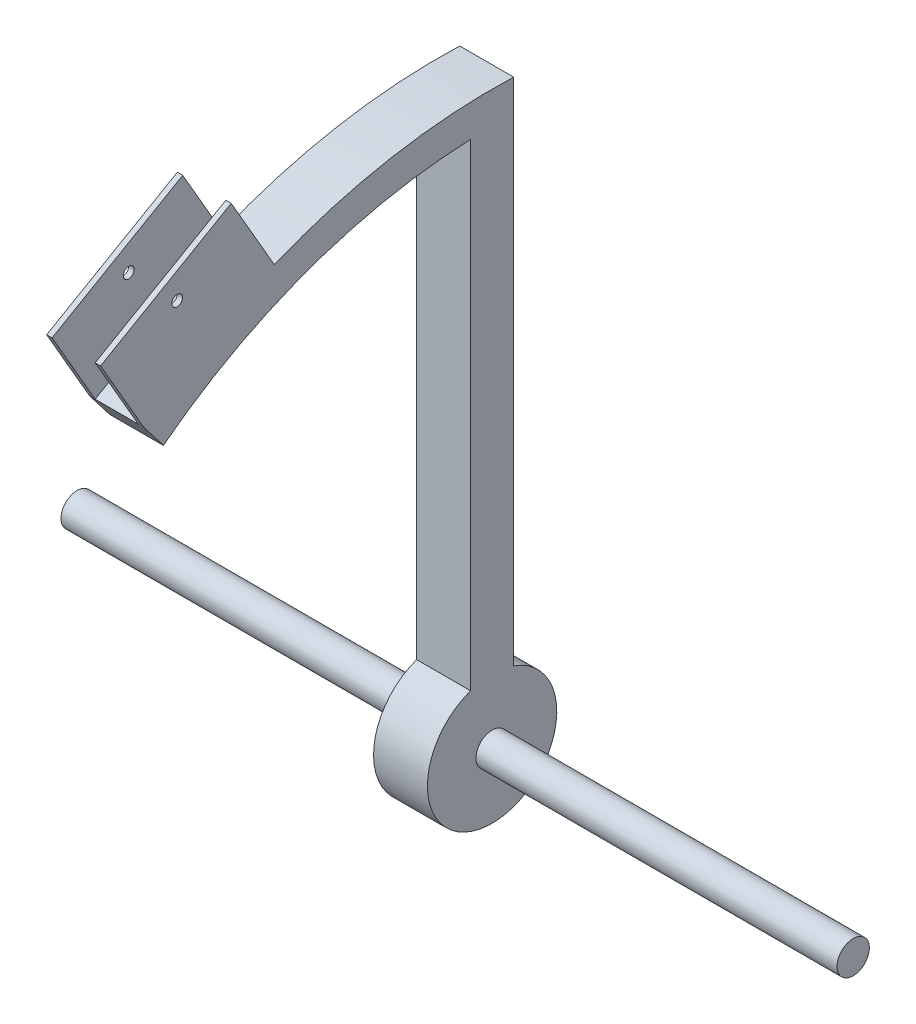
from build123d import *

# Parameters (mm, degrees)
BOSS_EXTRUDE1_DEPTH      = 12.5
BOSS_EXTRUDE1_DEPTH_BACK = 12.5
SKETCH11_R               = 7.5
BOSS_EXTRUDE4_DEPTH      = 180
BOSS_EXTRUDE4_DEPTH_BACK = 180
SKETCH12_W               = 25
SKETCH12_H               = 70
BOSS_EXTRUDE5_DEPTH      = 40
SKETCH13_W               = 20
SKETCH13_H               = 40
CUT_EXTRUDE2_DEPTH       = 70
SKETCH15_R               = 2.5
CUT_EXTRUDE3_DEPTH       = 191
CUT_EXTRUDE3_DEPTH_BACK  = 171
BOSS_EXTRUDE8_DEPTH      = 20


with BuildPart() as part:
    # Sketch1 → Boss-Extrude1 (new body, two sides)
    with BuildSketch(Plane(origin=(0, 0, 0), x_dir=(0, 0, -1), z_dir=(1, 0, 0))) as boss_extrude1_sk:
        with BuildLine():
            Line((10, 28.284271247), (10, 264.811253537))
            ThreePointArc((10, 264.811253537), (-46.581095136, 260.873918926), (-101.028366233, 244.986263322))
            Line((-101.028366233, 244.986263322), (-161.650144498, 209.986263322))
            Line((-161.650144498, 209.986263322), (-152.500136319, 198.100248417))
            ThreePointArc((-152.500136319, 198.100248417), (-85.263049352, 235.011089984), (-10, 249.799919936))
            Line((-10, 249.799919936), (-10, 28.284271247))
            ThreePointArc((-10, 28.284271247), (0, -30), (10, 28.284271247))
        make_face()
    extrude(amount=BOSS_EXTRUDE1_DEPTH)
    extrude(boss_extrude1_sk.sketch, amount=-BOSS_EXTRUDE1_DEPTH_BACK)

    # Sketch11 → Boss-Extrude4 (add, two sides)
    with BuildSketch(Plane(origin=(0, 0, 0), x_dir=(0, 0, -1), z_dir=(1, 0, 0))) as boss_extrude4_sk:
        Circle(SKETCH11_R)
    extrude(amount=BOSS_EXTRUDE4_DEPTH)
    extrude(boss_extrude4_sk.sketch, amount=-BOSS_EXTRUDE4_DEPTH_BACK)

    # Sketch12 → Boss-Extrude5 (add)
    with BuildSketch(Plane(origin=(0, 227.486263322, 131.339255366), x_dir=(1, 0, 0), z_dir=(0, 0.866025404, 0.5))):
        Rectangle(SKETCH12_W, SKETCH12_H)
    extrude(amount=BOSS_EXTRUDE5_DEPTH)

    # Sketch13 → Cut-Extrude2 (cut)
    with BuildSketch(Plane(origin=(0, 17.5, -30.310889132), x_dir=(-1, 0, 0), z_dir=(0, 0.5, -0.866025404))):
        with Locations((0, 282.678510731)):
            Rectangle(SKETCH13_W, SKETCH13_H)
    extrude(amount=-CUT_EXTRUDE2_DEPTH, mode=Mode.SUBTRACT)

    # Sketch15 → Cut-Extrude3 (cut, two sides)
    with BuildSketch(Plane.ZY.offset(-10)) as cut_extrude3_sk:
        with Locations((146.114255366, 253.077314003)):
            Circle(SKETCH15_R)
    extrude(amount=CUT_EXTRUDE3_DEPTH, mode=Mode.SUBTRACT)
    extrude(cut_extrude3_sk.sketch, amount=-CUT_EXTRUDE3_DEPTH_BACK, mode=Mode.SUBTRACT)

    # Sketch16 → Boss-Extrude8 (add)
    with BuildSketch(Plane.ZY.offset(-10)):
        Polygon((122.098874309, 241.48145385), (124.598874309, 245.811580869), (150.579636422, 230.811580869), (148.079636422, 226.48145385), align=None)
    extrude(amount=BOSS_EXTRUDE8_DEPTH)


solid = part.part
